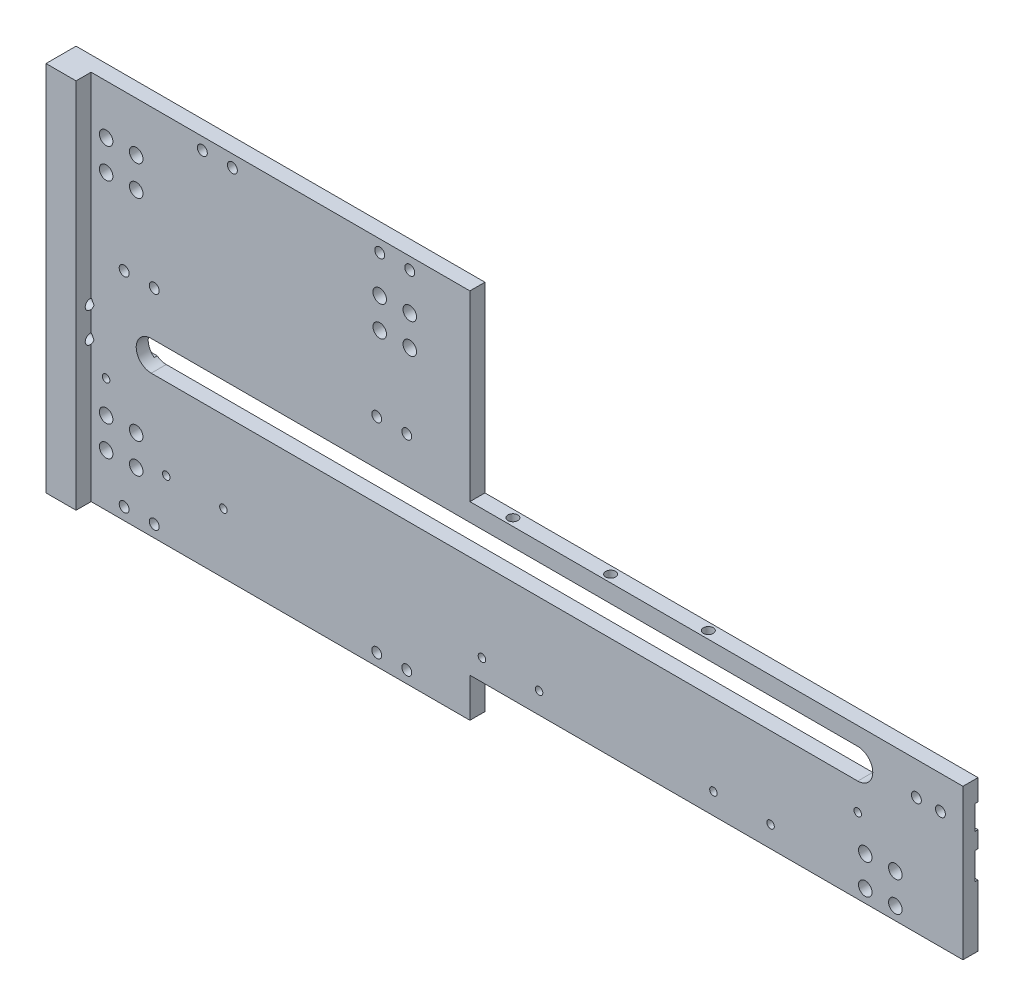
from build123d import *

# Parameters (mm, degrees)
EXTRUDE_1_DEPTH                  = 10
SKETCH_5_W                       = 1
SKETCH_5_H                       = 8
SKETCH_5_H_2                     = 9
CUT_EXTRUDE_1_DEPTH              = 301
HOLE_WIZARD_M4_1_D               = 3.3
HOLE_WIZARD_M4_1_DEPTH           = 10.1
HOLE_WIZARD_M4_1_TIP             = 0.991420021
SKETCH_8_W                       = 306.524855593
SKETCH_8_H                       = 162.762615977
CUT_EXTRUDE_2_DEPTH              = 5
HOLE_WIZARD_M4_2_AT_2_COUNT      = 2
HOLE_WIZARD_M4_2_AT_2_PITCH      = 10
HOLE_WIZARD_M4_2_AT_3_COUNT      = 2
HOLE_WIZARD_M4_2_AT_3_PITCH      = 84
HOLE_WIZARD_M4_2_AT_4_COUNT      = 2
HOLE_WIZARD_M4_2_AT_4_PITCH      = 94
HOLE_WIZARD_M4_2_AT_5_COUNT      = 2
HOLE_WIZARD_M4_2_AT_5_PITCH      = 68
HOLE_WIZARD_M4_2_AT_6_COUNT      = 2
HOLE_WIZARD_M4_2_AT_6_PITCH      = 68.73136111
HOLE_WIZARD_M4_2_AT_7_COUNT      = 2
HOLE_WIZARD_M4_2_AT_7_PITCH      = 108.074048689
HOLE_WIZARD_M4_2_AT_8_COUNT      = 2
HOLE_WIZARD_M4_2_AT_8_PITCH      = 116.017240098
HOLE_WIZARD_M4_2_AT_9_COUNT      = 2
HOLE_WIZARD_M4_2_AT_9_PITCH      = 118.585370093
HOLE_WIZARD_M4_2_AT_10_COUNT     = 2
HOLE_WIZARD_M4_2_AT_10_PITCH     = 121.171324991
HOLE_WIZARD_M4_2_AT_11_COUNT     = 2
HOLE_WIZARD_M4_2_AT_11_PITCH     = 143.567022676
HOLE_WIZARD_M4_2_AT_12_COUNT     = 2
HOLE_WIZARD_M4_2_AT_12_PITCH     = 149.704675946
HOLE_WIZARD_M3_1_D               = 2.5
HOLE_WIZARD_M3_1_DEPTH           = 7.5
HOLE_WIZARD_M3_1_TIP             = 0.751075774
HOLE_WIZARD_M3_2_D               = 2.5
HOLE_WIZARD_M3_2_DEPTH           = 7.5
HOLE_WIZARD_M3_2_TIP             = 0.751075774
SKETCH_15_R                      = 2.25
CUT_EXTRUDE_3_DEPTH              = 5
PATTERN_LINEAR_1_COUNT           = 2
PATTERN_LINEAR_1_PITCH           = 252.5
PATTERN_LINEAR_2_COUNT           = 2
PATTERN_LINEAR_2_PITCH           = 35
PATTERN_LINEAR_3_COUNT           = 2
PATTERN_LINEAR_3_PITCH           = 100
PATTERN_LINEAR_3_COPY_1_SKETCH_R = 2.25
PATTERN_LINEAR_3_COPY_1_DEPTH    = 5
SKETCH_16_W                      = 24.801944155
SKETCH_16_H                      = 22.086368347
EXTRUDE_2_DEPTH                  = 5
HOLE_WIZARD_M4_3_AT_2_COUNT      = 2
HOLE_WIZARD_M4_3_AT_2_PITCH      = 32.5
HOLE_WIZARD_M4_3_AT_3_COUNT      = 2
HOLE_WIZARD_M4_3_AT_3_PITCH      = 65
HOLE_WIZARD_M4_4_D               = 3.3
HOLE_WIZARD_M4_4_DEPTH           = 10.1
HOLE_WIZARD_M4_4_TIP             = 0.991420021
EXTRUDE_3_DEPTH                  = 47.7
SKETCH_24_W                      = 146.622122201
SKETCH_24_H                      = 84.687894877
CUT_EXTRUDE_4_DEPTH              = 47.7
PATTERN_LINEAR_4_COUNT           = 2
PATTERN_LINEAR_4_PITCH           = 80
SKETCH_25_R                      = 2.25
CUT_EXTRUDE_5_DEPTH              = 10


with BuildPart() as part:
    # 草图4 → 凸台-拉伸1 (new body)
    with BuildSketch(Plane.XY):
        Polygon((0, 0), (136, 0), (136, 60.7), (300, 60.7), (300, 110.7), (136, 110.7), (136, 123.7), (0, 123.7), align=None)
        with BuildLine():
            Line((30, 104.7), (265, 104.7))
            ThreePointArc((265, 104.7), (270, 99.7), (265, 94.7))
            Line((265, 94.7), (30, 94.7))
            ThreePointArc((30, 94.7), (25, 99.7), (30, 104.7))
        make_face(mode=Mode.SUBTRACT)
    extrude(amount=EXTRUDE_1_DEPTH)

    # 草图5 → 切除-拉伸1 (cut, through all)
    with BuildSketch(Plane(origin=(300, 0, 0), x_dir=(0, 0, -1), z_dir=(1, 0, 0))):
        with Locations((-0.5, 99.7)):
            Rectangle(SKETCH_5_W, SKETCH_5_H)
        with Locations((-0.5, 85.7)):
            Rectangle(SKETCH_5_W, SKETCH_5_H_2)
    extrude(amount=-CUT_EXTRUDE_1_DEPTH, mode=Mode.SUBTRACT)

    # M4 螺纹孔1
    with Locations(Plane.ZY):
        with Locations((5.304017572, 104.7), (5.304017572, 94.7)):
            Hole(HOLE_WIZARD_M4_1_D / 2, depth=HOLE_WIZARD_M4_1_DEPTH)
            with Locations((0, 0, -(HOLE_WIZARD_M4_1_DEPTH + HOLE_WIZARD_M4_1_TIP / 2))):  # 118° drill point
                Cone(0, HOLE_WIZARD_M4_1_D / 2, HOLE_WIZARD_M4_1_TIP, mode=Mode.SUBTRACT)

    # 草图8 → 切除-拉伸2 (cut)
    with BuildSketch(Plane.XY.offset(10)):
        with Locations((163.262427797, 42.318692012)):
            Rectangle(SKETCH_8_W, SKETCH_8_H)
    extrude(amount=-CUT_EXTRUDE_2_DEPTH, mode=Mode.SUBTRACT)

    # 草图10 → M4 螺纹孔2 (revolve, cut)
    with BuildSketch(Plane(origin=(21, 119.7, 5), x_dir=(0, -1, 0), z_dir=(1, 0, 0))):
        Polygon((0, 0), (0, 11.091420021), (1.65, 10.1), (1.65, 0), align=None)
    hole_wizard_m4_2 = revolve(axis=Axis((21, 119.7, 11.35), (0, 0, -1)), mode=Mode.SUBTRACT)

    # M4 螺纹孔2 at 2: M4 螺纹孔2 ×2
    with Locations(*[(i * HOLE_WIZARD_M4_2_AT_2_PITCH, 0, 0) for i in range(1, HOLE_WIZARD_M4_2_AT_2_COUNT)]):
        add(hole_wizard_m4_2, mode=Mode.SUBTRACT)

    # M4 螺纹孔2 at 3: M4 螺纹孔2 ×2
    with Locations(*[(i * HOLE_WIZARD_M4_2_AT_3_PITCH, 0, 0) for i in range(1, HOLE_WIZARD_M4_2_AT_3_COUNT)]):
        add(hole_wizard_m4_2, mode=Mode.SUBTRACT)

    # M4 螺纹孔2 at 4: M4 螺纹孔2 ×2
    with Locations(*[(i * HOLE_WIZARD_M4_2_AT_4_PITCH, 0, 0) for i in range(1, HOLE_WIZARD_M4_2_AT_4_COUNT)]):
        add(hole_wizard_m4_2, mode=Mode.SUBTRACT)

    # M4 螺纹孔2 at 5: M4 螺纹孔2 ×2
    with Locations(*[(0, -i * HOLE_WIZARD_M4_2_AT_5_PITCH, 0) for i in range(1, HOLE_WIZARD_M4_2_AT_5_COUNT)]):
        add(hole_wizard_m4_2, mode=Mode.SUBTRACT)

    # M4 螺纹孔2 at 6: M4 螺纹孔2 ×2
    with Locations(*[Vector(0.14549399, -0.989359135, 0) * (i * HOLE_WIZARD_M4_2_AT_6_PITCH) for i in range(1, HOLE_WIZARD_M4_2_AT_6_COUNT)]):
        add(hole_wizard_m4_2, mode=Mode.SUBTRACT)

    # M4 螺纹孔2 at 7: M4 螺纹孔2 ×2
    with Locations(*[Vector(0.777244871, -0.629198229, 0) * (i * HOLE_WIZARD_M4_2_AT_7_PITCH) for i in range(1, HOLE_WIZARD_M4_2_AT_7_COUNT)]):
        add(hole_wizard_m4_2, mode=Mode.SUBTRACT)

    # M4 螺纹孔2 at 8: M4 螺纹孔2 ×2
    with Locations(*[Vector(0.810224411, -0.586119787, 0) * (i * HOLE_WIZARD_M4_2_AT_8_PITCH) for i in range(1, HOLE_WIZARD_M4_2_AT_8_COUNT)]):
        add(hole_wizard_m4_2, mode=Mode.SUBTRACT)

    # M4 螺纹孔2 at 9: M4 螺纹孔2 ×2
    with Locations(*[Vector(0.219251329, -0.975668414, 0) * (i * HOLE_WIZARD_M4_2_AT_9_PITCH) for i in range(1, HOLE_WIZARD_M4_2_AT_9_COUNT)]):
        add(hole_wizard_m4_2, mode=Mode.SUBTRACT)

    # M4 螺纹孔2 at 10: M4 螺纹孔2 ×2
    with Locations(*[Vector(0.297099995, -0.954846372, 0) * (i * HOLE_WIZARD_M4_2_AT_10_PITCH) for i in range(1, HOLE_WIZARD_M4_2_AT_10_COUNT)]):
        add(hole_wizard_m4_2, mode=Mode.SUBTRACT)

    # M4 螺纹孔2 at 11: M4 螺纹孔2 ×2
    with Locations(*[Vector(0.59205797, -0.805895378, 0) * (i * HOLE_WIZARD_M4_2_AT_11_PITCH) for i in range(1, HOLE_WIZARD_M4_2_AT_11_COUNT)]):
        add(hole_wizard_m4_2, mode=Mode.SUBTRACT)

    # M4 螺纹孔2 at 12: M4 螺纹孔2 ×2
    with Locations(*[Vector(0.634582717, -0.772854951, 0) * (i * HOLE_WIZARD_M4_2_AT_12_PITCH) for i in range(1, HOLE_WIZARD_M4_2_AT_12_COUNT)]):
        add(hole_wizard_m4_2, mode=Mode.SUBTRACT)

    # M3 螺纹孔1
    with Locations(Plane.XY.offset(5)):
        with Locations((15, 85.7), (265, 85.7)):
            Hole(HOLE_WIZARD_M3_1_D / 2, depth=HOLE_WIZARD_M3_1_DEPTH)
            with Locations((0, 0, -(HOLE_WIZARD_M3_1_DEPTH + HOLE_WIZARD_M3_1_TIP / 2))):  # 118° drill point
                Cone(0, HOLE_WIZARD_M3_1_D / 2, HOLE_WIZARD_M3_1_TIP, mode=Mode.SUBTRACT)

    # M3 螺纹孔2
    with Locations(Plane.XY.offset(5)):
        with Locations((35, 67.7), (54, 67.7), (140, 67.7), (159, 67.7), (217, 67.7), (236, 67.7)):
            Hole(HOLE_WIZARD_M3_2_D / 2, depth=HOLE_WIZARD_M3_2_DEPTH)
            with Locations((0, 0, -(HOLE_WIZARD_M3_2_DEPTH + HOLE_WIZARD_M3_2_TIP / 2))):  # 118° drill point
                Cone(0, HOLE_WIZARD_M3_2_D / 2, HOLE_WIZARD_M3_2_TIP, mode=Mode.SUBTRACT)

    # 草图15 → 切除-拉伸3 (cut)
    with BuildSketch(Plane.XY.offset(5)):
        with Locations((15, 75)):
            Circle(SKETCH_15_R)
        with Locations((25, 75)):
            Circle(SKETCH_15_R)
        with Locations((25, 65)):
            Circle(SKETCH_15_R)
        with Locations((15, 65)):
            Circle(SKETCH_15_R)
    cut_extrude_3 = extrude(amount=-CUT_EXTRUDE_3_DEPTH, mode=Mode.SUBTRACT)

    # 阵列(线性)1: 切除-拉伸3 ×2
    with Locations(*[(i * PATTERN_LINEAR_1_PITCH, 0, 0) for i in range(1, PATTERN_LINEAR_1_COUNT)]):
        add(cut_extrude_3, mode=Mode.SUBTRACT)

    # 阵列(线性)2: 切除-拉伸3 ×2
    with Locations(*[(0, -i * PATTERN_LINEAR_2_PITCH, 0) for i in range(1, PATTERN_LINEAR_2_COUNT)]):
        add(cut_extrude_3, mode=Mode.SUBTRACT)

    # 阵列(线性)3: 切除-拉伸3 ×2
    with Locations(*[(i * PATTERN_LINEAR_3_PITCH, 0, 0) for i in range(1, PATTERN_LINEAR_3_COUNT)]):
        add(cut_extrude_3, mode=Mode.SUBTRACT)

    # 阵列(线性)3 copy 1 sketch → 阵列(线性)3 copy 1 (cut)
    with BuildSketch(Plane(origin=(100, -35, 5), x_dir=(1, 0, 0), z_dir=(0, 0, 1))):
        with Locations((15, 75)):
            Circle(PATTERN_LINEAR_3_COPY_1_SKETCH_R)
        with Locations((25, 75)):
            Circle(PATTERN_LINEAR_3_COPY_1_SKETCH_R)
        with Locations((25, 65)):
            Circle(PATTERN_LINEAR_3_COPY_1_SKETCH_R)
        with Locations((15, 65)):
            Circle(PATTERN_LINEAR_3_COPY_1_SKETCH_R)
    extrude(amount=-PATTERN_LINEAR_3_COPY_1_DEPTH, mode=Mode.SUBTRACT)

    # 草图16 → 凸台-拉伸2 (add)
    with BuildSketch(Plane.XY.offset(5)):
        with Locations((117.7891907, 70.013681934)):
            Rectangle(SKETCH_16_W, SKETCH_16_H)
    extrude(amount=-EXTRUDE_2_DEPTH)

    # 草图18 → M4 螺纹孔3 (revolve, cut)
    with BuildSketch(Plane(origin=(147.8, 60.7, 2.5), x_dir=(0, 0, -1), z_dir=(1, 0, 0))):
        Polygon((0, 0), (0, 11.091420021), (1.65, 10.1), (1.65, 0), align=None)
    hole_wizard_m4_3 = revolve(axis=Axis((147.8, 54.35, 2.5), (0, 1, 0)), mode=Mode.SUBTRACT)

    # M4 螺纹孔3 at 2: M4 螺纹孔3 ×2
    with Locations(*[(i * HOLE_WIZARD_M4_3_AT_2_PITCH, 0, 0) for i in range(1, HOLE_WIZARD_M4_3_AT_2_COUNT)]):
        add(hole_wizard_m4_3, mode=Mode.SUBTRACT)

    # M4 螺纹孔3 at 3: M4 螺纹孔3 ×2
    with Locations(*[(i * HOLE_WIZARD_M4_3_AT_3_PITCH, 0, 0) for i in range(1, HOLE_WIZARD_M4_3_AT_3_COUNT)]):
        add(hole_wizard_m4_3, mode=Mode.SUBTRACT)

    # 镜向1: M4 螺纹孔3 across plane
    add(hole_wizard_m4_3.mirror(Plane(origin=(0, 85.7, 0), x_dir=(0, 0, 1), z_dir=(0, -1, 0))), mode=Mode.SUBTRACT)

    # 镜向1 copy 1 sketch → 镜向1 copy 1 (revolve, cut)
    with BuildSketch(Plane(origin=(180.3, 110.7, 2.5), x_dir=(0, 0, -1), z_dir=(1, 0, 0))):
        Polygon((0, 0), (0, -11.091420021), (1.65, -10.1), (1.65, 0), align=None)
    revolve(axis=Axis((180.3, 117.05, 2.5), (0, 1, 0)), mode=Mode.SUBTRACT)

    # 镜向1 copy 2 sketch → 镜向1 copy 2 (revolve, cut)
    with BuildSketch(Plane(origin=(212.8, 110.7, 2.5), x_dir=(0, 0, -1), z_dir=(1, 0, 0))):
        Polygon((0, 0), (0, -11.091420021), (1.65, -10.1), (1.65, 0), align=None)
    revolve(axis=Axis((212.8, 117.05, 2.5), (0, 1, 0)), mode=Mode.SUBTRACT)

    # M4 螺纹孔4
    with Locations(Plane(origin=(0, 0, 1), x_dir=(-1, 0, 0), z_dir=(0, 0, -1))):
        with Locations((-284.5, 99.7), (-292.5, 99.7)):
            Hole(HOLE_WIZARD_M4_4_D / 2, depth=HOLE_WIZARD_M4_4_DEPTH)
            with Locations((0, 0, -(HOLE_WIZARD_M4_4_DEPTH + HOLE_WIZARD_M4_4_TIP / 2))):  # 118° drill point
                Cone(0, HOLE_WIZARD_M4_4_D / 2, HOLE_WIZARD_M4_4_TIP, mode=Mode.SUBTRACT)

    # 草图21 → 凸台-拉伸3 (add)
    with BuildSketch(Plane(origin=(0, 123.7, 0), x_dir=(1, 0, 0), z_dir=(0, 1, 0))):
        Polygon((0, -10), (0, 0), (136, 0), (136, -5), (10, -5), (10, -10), align=None)
    extrude(amount=EXTRUDE_3_DEPTH)

    # 镜向2: M4 螺纹孔2 across plane
    add(hole_wizard_m4_2.mirror(Plane(origin=(0, 85.7, 0), x_dir=(0, 0, 1), z_dir=(0, -1, 0))), mode=Mode.SUBTRACT)

    # 镜向2 copy 1 sketch → 镜向2 copy 1 (revolve, cut)
    with BuildSketch(Plane(origin=(31, 51.7, 5), x_dir=(0, 1, 0), z_dir=(1, 0, 0))):
        Polygon((0, 0), (0, -11.091420021), (1.65, -10.1), (1.65, 0), align=None)
    revolve(axis=Axis((31, 51.7, 11.35), (0, 0, 1)), mode=Mode.SUBTRACT)

    # 镜向2 copy 2 sketch → 镜向2 copy 2 (revolve, cut)
    with BuildSketch(Plane(origin=(105, 51.7, 5), x_dir=(0, 1, 0), z_dir=(1, 0, 0))):
        Polygon((0, 0), (0, -11.091420021), (1.65, -10.1), (1.65, 0), align=None)
    revolve(axis=Axis((105, 51.7, 11.35), (0, 0, 1)), mode=Mode.SUBTRACT)

    # 镜向2 copy 3 sketch → 镜向2 copy 3 (revolve, cut)
    with BuildSketch(Plane(origin=(115, 51.7, 5), x_dir=(0, 1, 0), z_dir=(1, 0, 0))):
        Polygon((0, 0), (0, -11.091420021), (1.65, -10.1), (1.65, 0), align=None)
    revolve(axis=Axis((115, 51.7, 11.35), (0, 0, 1)), mode=Mode.SUBTRACT)

    # 镜向2 copy 4 sketch → 镜向2 copy 4 (revolve, cut)
    with BuildSketch(Plane(origin=(21, 119.7, 5), x_dir=(0, 1, 0), z_dir=(1, 0, 0))):
        Polygon((0, 0), (0, -11.091420021), (1.65, -10.1), (1.65, 0), align=None)
    revolve(axis=Axis((21, 119.7, 11.35), (0, 0, 1)), mode=Mode.SUBTRACT)

    # 镜向2 copy 5 sketch → 镜向2 copy 5 (revolve, cut)
    with BuildSketch(Plane(origin=(31, 119.7, 5), x_dir=(0, 1, 0), z_dir=(1, 0, 0))):
        Polygon((0, 0), (0, -11.091420021), (1.65, -10.1), (1.65, 0), align=None)
    revolve(axis=Axis((31, 119.7, 11.35), (0, 0, 1)), mode=Mode.SUBTRACT)

    # 镜向2 copy 6 sketch → 镜向2 copy 6 (revolve, cut)
    with BuildSketch(Plane(origin=(105, 119.7, 5), x_dir=(0, 1, 0), z_dir=(1, 0, 0))):
        Polygon((0, 0), (0, -11.091420021), (1.65, -10.1), (1.65, 0), align=None)
    revolve(axis=Axis((105, 119.7, 11.35), (0, 0, 1)), mode=Mode.SUBTRACT)

    # 镜向2 copy 7 sketch → 镜向2 copy 7 (revolve, cut)
    with BuildSketch(Plane(origin=(115, 119.7, 5), x_dir=(0, 1, 0), z_dir=(1, 0, 0))):
        Polygon((0, 0), (0, -11.091420021), (1.65, -10.1), (1.65, 0), align=None)
    revolve(axis=Axis((115, 119.7, 11.35), (0, 0, 1)), mode=Mode.SUBTRACT)

    # 镜向2 copy 8 sketch → 镜向2 copy 8 (revolve, cut)
    with BuildSketch(Plane(origin=(47, 167.4, 5), x_dir=(0, 1, 0), z_dir=(1, 0, 0))):
        Polygon((0, 0), (0, -11.091420021), (1.65, -10.1), (1.65, 0), align=None)
    revolve(axis=Axis((47, 167.4, 11.35), (0, 0, 1)), mode=Mode.SUBTRACT)

    # 镜向2 copy 9 sketch → 镜向2 copy 9 (revolve, cut)
    with BuildSketch(Plane(origin=(57, 167.4, 5), x_dir=(0, 1, 0), z_dir=(1, 0, 0))):
        Polygon((0, 0), (0, -11.091420021), (1.65, -10.1), (1.65, 0), align=None)
    revolve(axis=Axis((57, 167.4, 11.35), (0, 0, 1)), mode=Mode.SUBTRACT)

    # 镜向2 copy 10 sketch → 镜向2 copy 10 (revolve, cut)
    with BuildSketch(Plane(origin=(106, 167.4, 5), x_dir=(0, 1, 0), z_dir=(1, 0, 0))):
        Polygon((0, 0), (0, -11.091420021), (1.65, -10.1), (1.65, 0), align=None)
    revolve(axis=Axis((106, 167.4, 11.35), (0, 0, 1)), mode=Mode.SUBTRACT)

    # 镜向2 copy 11 sketch → 镜向2 copy 11 (revolve, cut)
    with BuildSketch(Plane(origin=(116, 167.4, 5), x_dir=(0, 1, 0), z_dir=(1, 0, 0))):
        Polygon((0, 0), (0, -11.091420021), (1.65, -10.1), (1.65, 0), align=None)
    revolve(axis=Axis((116, 167.4, 11.35), (0, 0, 1)), mode=Mode.SUBTRACT)

    # 草图24 → 切除-拉伸4 (cut)
    with BuildSketch(Plane(origin=(0, 0, 0), x_dir=(-1, 0, 0), z_dir=(0, 0, -1))):
        with Locations((-73.3110611, 5.356052562)):
            Rectangle(SKETCH_24_W, SKETCH_24_H)
    extrude(amount=-CUT_EXTRUDE_4_DEPTH, mode=Mode.SUBTRACT)

    # 阵列(线性)4: 切除-拉伸3 ×2
    with Locations(*[(0, i * PATTERN_LINEAR_4_PITCH, 0) for i in range(1, PATTERN_LINEAR_4_COUNT)]):
        add(cut_extrude_3, mode=Mode.SUBTRACT)

    # 草图25 → 切除-拉伸5 (cut)
    with BuildSketch(Plane(origin=(0, 0, 0), x_dir=(-1, 0, 0), z_dir=(0, 0, -1))):
        with Locations((-106, 145)):
            Circle(SKETCH_25_R)
        with Locations((-116, 145)):
            Circle(SKETCH_25_R)
        with Locations((-116, 155)):
            Circle(SKETCH_25_R)
        with Locations((-106, 155)):
            Circle(SKETCH_25_R)
    extrude(amount=-CUT_EXTRUDE_5_DEPTH, mode=Mode.SUBTRACT)


solid = part.part
